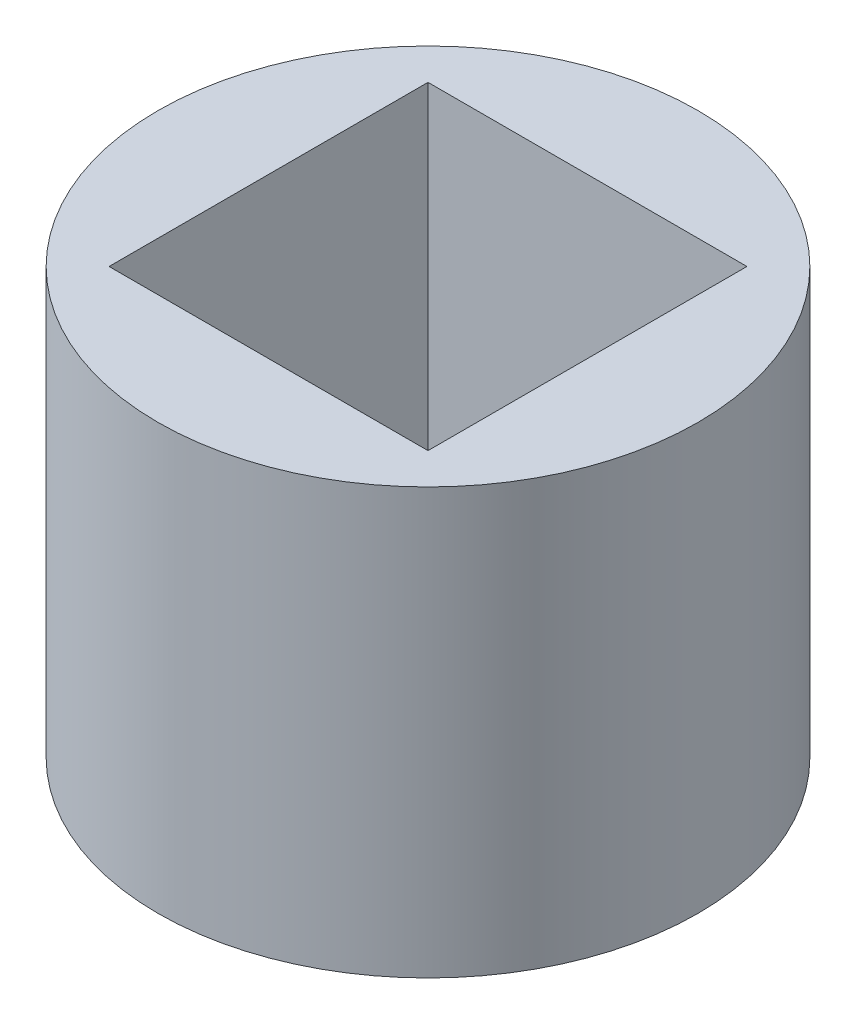
from build123d import *

# Parameters (mm, degrees)
SKETCH1_R           = 12.7
SKETCH1_W           = 15
SKETCH1_H           = 15
BOSS_EXTRUDE2_DEPTH = 20


with BuildPart() as part:
    # Sketch1 → Boss-Extrude2 (new body)
    with BuildSketch(Plane(origin=(0, 0, 0), x_dir=(1, 0, 0), z_dir=(0, 1, 0))):
        Circle(SKETCH1_R)
        Rectangle(SKETCH1_W, SKETCH1_H, mode=Mode.SUBTRACT)
    extrude(amount=BOSS_EXTRUDE2_DEPTH)


solid = part.part
